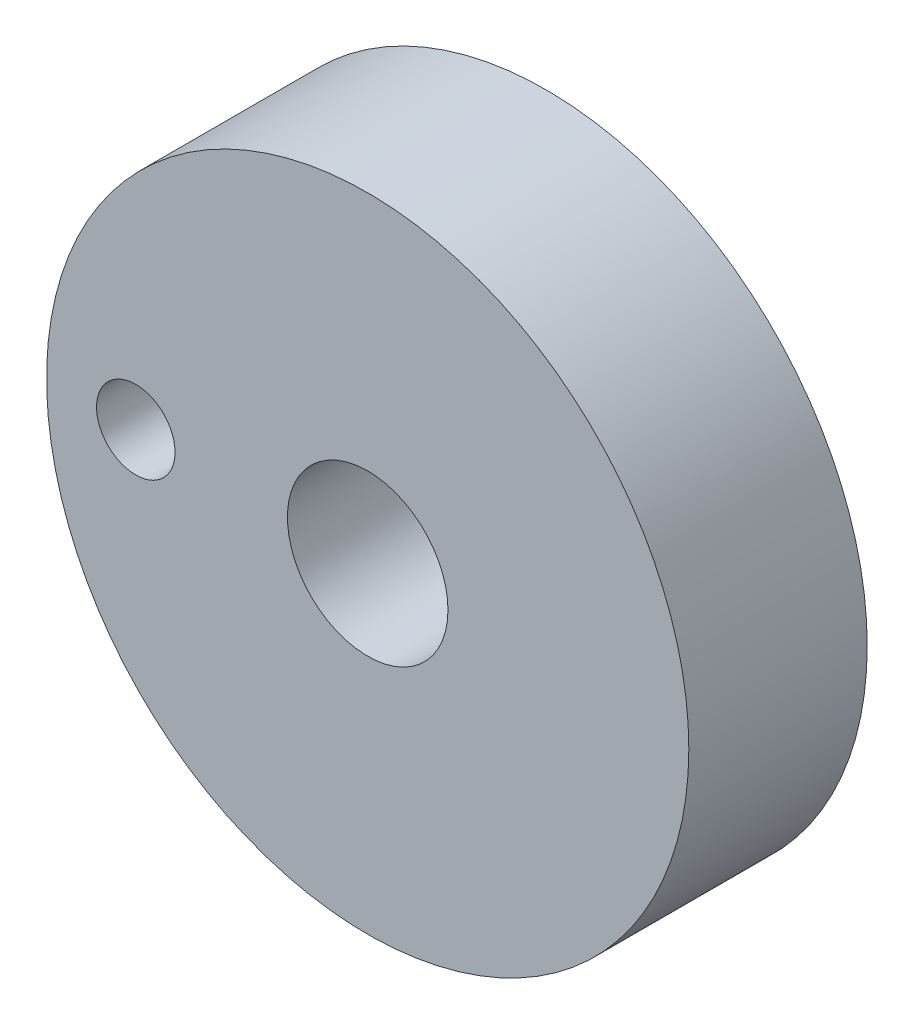
from build123d import *

# Parameters (mm, degrees)
SKETCH1_R           = 9
SKETCH1_R_2         = 2.25
SKETCH1_R_3         = 1.1
BOSS_EXTRUDE1_DEPTH = 5


with BuildPart() as part:
    # Sketch1 → Boss-Extrude1 (new body)
    with BuildSketch(Plane.XY):
        Circle(SKETCH1_R)
        Circle(SKETCH1_R_2, mode=Mode.SUBTRACT)
        with Locations((-6.5, 0)):
            Circle(SKETCH1_R_3, mode=Mode.SUBTRACT)
    extrude(amount=BOSS_EXTRUDE1_DEPTH)


solid = part.part
